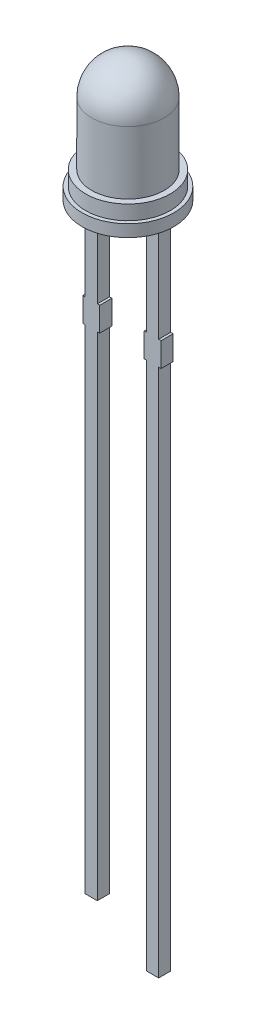
from build123d import *

# Parameters (mm, degrees)
SKETCH2_R          = 1.9
SKETCH2_R_2        = 1.75
EXTRUDE2_DEPTH     = 0.5
SKETCH2_3_R        = 1.75
EXTRUDE3_DEPTH     = 1.1
SKETCH3_3_W        = 0.5
SKETCH3_3_H        = 4.1
SKETCH3_3_H_2      = 1
SKETCH3_3_H_3      = 20.4
SKETCH3_3_W_2      = 0.1
SKETCH3_3_H_4      = 21.9
EXTRUDE4_DEPTH     = 0.25
CUT_EXTRUDE1_DEPTH = 0.01


with BuildPart() as part:
    # Sketch2 → Extrude2 (new body)
    with BuildSketch(Plane(origin=(0, 0, 0), x_dir=(1, 0, 0), z_dir=(0, 1, 0))):
        with Locations(Location((0, 0, 0), (0, 0, 270))):  # turned: the seam where the file's is
            Circle(SKETCH2_R)
        Circle(SKETCH2_R_2, mode=Mode.SUBTRACT)
        Circle(SKETCH2_R_2)
    extrude(amount=EXTRUDE2_DEPTH)

    # Sketch2_3 → Extrude3 (add)
    with BuildSketch(Plane(origin=(0, 0, 0), x_dir=(1, 0, 0), z_dir=(0, 1, 0))):
        with Locations(Location((0, 0, 0), (0, 0, 270))):  # turned: the seam where the file's is
            Circle(SKETCH2_3_R)
    extrude(amount=EXTRUDE3_DEPTH)

    # Sketch3 → Revolve1 (revolve)
    with BuildSketch(Plane.XY, mode=Mode.PRIVATE) as revolve1_sk:
        with BuildLine():
            ThreePointArc((0, 5.2), (1.060660172, 4.760660172), (1.5, 3.7))
            Line((1.5, 3.7), (1.5, 1.1))
            Line((1.5, 1.1), (0, 1.1))
            Line((0, 1.1), (0, 5.2))
        make_face()
    revolve(revolve1_sk.sketch.rotate(Axis((0, 1.1, 0), (0, 1, 0)), 270), axis=Axis((0, 1.1, 0), (0, 1, 0)))  # turned: the seam where the file's is

    # Sketch3_3 → Extrude4 (add, symmetric)
    with BuildSketch(Plane.XY):
        with Locations((-1.27, -2.05)):
            Rectangle(SKETCH3_3_W, SKETCH3_3_H)
        with Locations((-1.27, -4.6)):
            Rectangle(SKETCH3_3_W, SKETCH3_3_H_2)
        with Locations((-1.27, -15.3)):
            Rectangle(SKETCH3_3_W, SKETCH3_3_H_3)
        with Locations((-0.97, -4.6)):
            Rectangle(SKETCH3_3_W_2, SKETCH3_3_H_2)
        with Locations((-1.57, -4.6)):
            Rectangle(SKETCH3_3_W_2, SKETCH3_3_H_2)
        with Locations((1.27, -2.05)):
            Rectangle(SKETCH3_3_W, SKETCH3_3_H)
        with Locations((1.27, -4.6)):
            Rectangle(SKETCH3_3_W, SKETCH3_3_H_2)
        with Locations((0.97, -4.6)):
            Rectangle(SKETCH3_3_W_2, SKETCH3_3_H_2)
        with Locations((1.57, -4.6)):
            Rectangle(SKETCH3_3_W_2, SKETCH3_3_H_2)
        with Locations((1.27, -16.05)):
            Rectangle(SKETCH3_3_W, SKETCH3_3_H_4)
    extrude(amount=EXTRUDE4_DEPTH, both=True)

    # Sketch5 → Cut-Extrude1 (cut)
    with BuildSketch(Plane.XZ):
        Polygon((-0.503821859, -0.079608343), (-0.525576666, -0.152685266), (-0.541832676, -0.152685266), (-0.554062243, -0.101753776), (-0.567944455, -0.152685266), (-0.58411032, -0.152685266), (-0.605744936, -0.079608343), (-0.586994936, -0.079608343), (-0.576027388, -0.132432863), (-0.562956474, -0.079608343), (-0.544777388, -0.079608343), (-0.533359118, -0.132432863), (-0.522662003, -0.079608343), align=None)
        Polygon((-0.403821859, -0.079608343), (-0.425576666, -0.152685266), (-0.441832676, -0.152685266), (-0.454062243, -0.101753776), (-0.467944455, -0.152685266), (-0.48411032, -0.152685266), (-0.505744936, -0.079608343), (-0.486994936, -0.079608343), (-0.476027388, -0.132432863), (-0.462956474, -0.079608343), (-0.444777388, -0.079608343), (-0.433359118, -0.132432863), (-0.422662003, -0.079608343), align=None)
        Polygon((-0.303821859, -0.079608343), (-0.325576666, -0.152685266), (-0.341832676, -0.152685266), (-0.354062243, -0.101753776), (-0.367944455, -0.152685266), (-0.38411032, -0.152685266), (-0.405744936, -0.079608343), (-0.386994936, -0.079608343), (-0.376027388, -0.132432863), (-0.362956474, -0.079608343), (-0.344777388, -0.079608343), (-0.333359118, -0.132432863), (-0.322662003, -0.079608343), align=None)
        with BuildLine():
            add(Edge.make_bspline(
                [(-0.263437243, -0.140185266), (-0.263486727, -0.140892123), (-0.263589513, -0.142360404), (-0.264357807, -0.144504784), (-0.265496591, -0.146613821), (-0.267134075, -0.148533963), (-0.269231655, -0.150213853), (-0.271742782, -0.151593586), (-0.274683068, -0.152530556), (-0.276781381, -0.152632729), (-0.27786032, -0.152685266)],
                knots=[0, 0, 0, 0, 0.803957419, 1.669978378, 2.568830098, 3.52434643, 4.522321038, 5.61514242, 6.773720829, 8, 8, 8, 8], degree=3))
            add(Edge.make_bspline(
                [(-0.27786032, -0.152685266), (-0.278697543, -0.152641732), (-0.280376311, -0.152554437), (-0.282771356, -0.151766833), (-0.284945412, -0.150603694), (-0.286817544, -0.149054517), (-0.288276376, -0.147145358), (-0.289485961, -0.145048644), (-0.290224996, -0.142676212), (-0.29031489, -0.141021518), (-0.29036032, -0.140185266)],
                knots=[0, 0, 0, 0, 1.021956945, 2.049191568, 3.052757421, 4.027239216, 4.995768388, 5.977850542, 6.978043055, 8, 8, 8, 8], degree=3))
            add(Edge.make_bspline(
                [(-0.29036032, -0.140185266), (-0.290317026, -0.139348095), (-0.290231854, -0.137701173), (-0.28947004, -0.135355324), (-0.288323864, -0.133246603), (-0.286823688, -0.131379472), (-0.284984748, -0.12977993), (-0.282769165, -0.128652231), (-0.280383455, -0.127805435), (-0.278698903, -0.127725205), (-0.27786032, -0.127685266)],
                knots=[0, 0, 0, 0, 1.02256761, 2.011643391, 2.988402578, 3.947919371, 4.930894396, 5.945859716, 6.97743239, 8, 8, 8, 8], degree=3))
            add(Edge.make_bspline(
                [(-0.27786032, -0.127685266), (-0.276809681, -0.12773535), (-0.274735014, -0.127834249), (-0.271838649, -0.128841062), (-0.269237757, -0.130131922), (-0.267164407, -0.13189148), (-0.265493452, -0.133795438), (-0.264322082, -0.135875074), (-0.263594766, -0.138025011), (-0.263488734, -0.139479135), (-0.263437243, -0.140185266)],
                knots=[0, 0, 0, 0, 1.193718436, 2.357200027, 3.46616707, 4.488721408, 5.436751473, 6.342315378, 7.195018269, 8, 8, 8, 8], degree=3))
        make_face()
        with BuildLine():
            add(Edge.make_bspline(
                [(-0.203100705, -0.154608343), (-0.204814974, -0.154585883), (-0.208130579, -0.154542441), (-0.212935142, -0.154027673), (-0.217416087, -0.153318314), (-0.221556667, -0.152225485), (-0.225361515, -0.150850333), (-0.228836787, -0.149171492), (-0.232054021, -0.147304786), (-0.234910629, -0.145081561), (-0.237469593, -0.142664532), (-0.239689243, -0.140000479), (-0.241624731, -0.137158483), (-0.243214822, -0.134031891), (-0.244455434, -0.130591099), (-0.245334898, -0.126767024), (-0.245946211, -0.122555462), (-0.246066822, -0.119604606), (-0.246129551, -0.118069882)],
                knots=[0, 0, 0, 0, 1.28338536, 2.482222902, 3.615641418, 4.678302996, 5.684574369, 6.640891817, 7.565949061, 8.464746586, 9.345581526, 10.197575617, 11.056903422, 11.91580542, 12.817603529, 13.789275343, 14.850214295, 16, 16, 16, 16], degree=3))
            Line((-0.246129551, -0.118069882), (-0.227109118, -0.118069882))
            add(Edge.make_bspline(
                [(-0.227109118, -0.118069882), (-0.226986998, -0.119294298), (-0.226756627, -0.121604063), (-0.226159906, -0.124820467), (-0.225407892, -0.127595585), (-0.224389822, -0.129922514), (-0.223231903, -0.131907604), (-0.221939877, -0.133640233), (-0.220584372, -0.135201808), (-0.218602446, -0.136973774), (-0.215830994, -0.1387379), (-0.212116798, -0.140200499), (-0.208023078, -0.141002153), (-0.205177484, -0.141097405), (-0.203701666, -0.141146805)],
                knots=[0, 0, 0, 0, 1.193967772, 2.252326225, 3.172507138, 3.978093684, 4.710151129, 5.398551009, 6.073569162, 6.713873795, 7.973381569, 9.239028936, 10.568070259, 12, 12, 12, 12], degree=3))
            add(Edge.make_bspline(
                [(-0.203701666, -0.141146805), (-0.202134828, -0.141102677), (-0.199167845, -0.141019116), (-0.194986092, -0.140190627), (-0.191343986, -0.138900009), (-0.188278009, -0.137080842), (-0.185834196, -0.134833314), (-0.183995897, -0.132228144), (-0.18285042, -0.129206008), (-0.182730161, -0.127054397), (-0.182668013, -0.125942478)],
                knots=[0, 0, 0, 0, 1.292881893, 2.448216373, 3.505729005, 4.47062867, 5.372299035, 6.228402631, 7.084466243, 8, 8, 8, 8], degree=3))
            add(Edge.make_bspline(
                [(-0.182668013, -0.125942478), (-0.182721517, -0.124822933), (-0.182820838, -0.122744675), (-0.183659336, -0.120299705), (-0.184707409, -0.118677821), (-0.185697877, -0.117543914), (-0.186929699, -0.116471806), (-0.188412505, -0.115490457), (-0.190161617, -0.114557564), (-0.192160794, -0.11362566), (-0.194466584, -0.112762806), (-0.197057579, -0.111925823), (-0.199963537, -0.111101525), (-0.203172508, -0.110167392), (-0.206756434, -0.109334568), (-0.209250991, -0.10873651), (-0.210552628, -0.108424449)],
                knots=[0, 0, 0, 0, 1.308217091, 2.428499093, 2.971811445, 3.562083625, 4.185450824, 4.878313926, 5.639298351, 6.505129032, 7.459166185, 8.51991211, 9.692741175, 10.996059842, 12.432571982, 14, 14, 14, 14], degree=3))
            add(Edge.make_bspline(
                [(-0.210552628, -0.108424449), (-0.211836723, -0.108112066), (-0.214325325, -0.10750666), (-0.217940452, -0.106484683), (-0.221302917, -0.10534421), (-0.224455444, -0.104154737), (-0.227346226, -0.102829375), (-0.229997306, -0.101399394), (-0.23237282, -0.099831824), (-0.234499885, -0.098180881), (-0.236356204, -0.096389924), (-0.237959605, -0.094455661), (-0.239317243, -0.092382215), (-0.240415569, -0.090151978), (-0.241252306, -0.087769484), (-0.241853475, -0.085221755), (-0.242218017, -0.082513548), (-0.242261271, -0.080651161), (-0.242283397, -0.079698488)],
                knots=[0, 0, 0, 0, 1.350138021, 2.616595417, 3.836558268, 4.976793827, 6.057431512, 7.083186274, 8.051004732, 8.961973241, 9.830394181, 10.680720399, 11.523687559, 12.356594861, 13.21427804, 14.097880016, 15.027001965, 16, 16, 16, 16], degree=3))
            add(Edge.make_bspline(
                [(-0.242283397, -0.079698488), (-0.242243964, -0.078665309), (-0.242166202, -0.076627894), (-0.241693688, -0.07363471), (-0.240829468, -0.070776371), (-0.239658736, -0.068045876), (-0.238192264, -0.065460999), (-0.236419325, -0.063067455), (-0.234414286, -0.060844368), (-0.232134525, -0.058813442), (-0.229611232, -0.056993699), (-0.226866576, -0.055351626), (-0.223866748, -0.053978199), (-0.22065337, -0.052805652), (-0.217236142, -0.051878377), (-0.213648115, -0.051222822), (-0.209910813, -0.050821613), (-0.20736855, -0.050782224), (-0.206075465, -0.050762189)],
                knots=[0, 0, 0, 0, 0.957814223, 1.888799201, 2.799332819, 3.718439235, 4.637311203, 5.547134667, 6.473851604, 7.407471124, 8.371205588, 9.353539842, 10.366965553, 11.424217362, 12.520959394, 13.644407811, 14.801862002, 16, 16, 16, 16], degree=3))
            add(Edge.make_bspline(
                [(-0.206075465, -0.050762189), (-0.204622608, -0.050796636), (-0.201771766, -0.050864227), (-0.197576664, -0.051230223), (-0.193578081, -0.051978249), (-0.189745153, -0.052923965), (-0.186126317, -0.054149423), (-0.182730629, -0.055622578), (-0.179599692, -0.057363678), (-0.176748292, -0.059357591), (-0.174153014, -0.061507811), (-0.171879103, -0.063854155), (-0.169980353, -0.066399677), (-0.168381922, -0.069123299), (-0.167078752, -0.072138931), (-0.166178881, -0.075551552), (-0.165578707, -0.079368622), (-0.165435394, -0.08204991), (-0.16536032, -0.083454497)],
                knots=[0, 0, 0, 0, 1.186950675, 2.32907279, 3.434719709, 4.506181443, 5.551366779, 6.551492465, 7.525684865, 8.472032948, 9.389619293, 10.274870494, 11.133875947, 11.977154569, 12.849419986, 13.808029842, 14.851741326, 16, 16, 16, 16], degree=3))
            Line((-0.16536032, -0.083454497), (-0.184440849, -0.083454497))
            add(Edge.make_bspline(
                [(-0.184440849, -0.083454497), (-0.184633942, -0.081943168), (-0.185000689, -0.079072645), (-0.186262262, -0.075089431), (-0.188114566, -0.071720799), (-0.190504546, -0.0689196), (-0.193502328, -0.066781919), (-0.197046996, -0.065271878), (-0.201123558, -0.064374713), (-0.204017421, -0.064275659), (-0.205534599, -0.064223728)],
                knots=[0, 0, 0, 0, 1.138878594, 2.163113395, 3.106118689, 3.999005743, 4.895818561, 5.835958478, 6.865448045, 8, 8, 8, 8], degree=3))
            add(Edge.make_bspline(
                [(-0.205534599, -0.064223728), (-0.206858901, -0.064271531), (-0.209365558, -0.064362012), (-0.212913527, -0.064987723), (-0.215959191, -0.066178946), (-0.218553684, -0.067764277), (-0.220597408, -0.069857544), (-0.222043307, -0.072423353), (-0.222934148, -0.075423889), (-0.223011907, -0.077578553), (-0.223052628, -0.078706901)],
                knots=[0, 0, 0, 0, 1.229005574, 2.326279772, 3.32381644, 4.246881527, 5.127569263, 6.005949281, 6.955762047, 8, 8, 8, 8], degree=3))
            add(Edge.make_bspline(
                [(-0.223052628, -0.078706901), (-0.223012129, -0.079731993), (-0.222937918, -0.081610362), (-0.222271811, -0.084204404), (-0.220991467, -0.086248918), (-0.219213057, -0.087966144), (-0.216687601, -0.089318378), (-0.21342865, -0.090670661), (-0.20925811, -0.091966621), (-0.206150471, -0.092718986), (-0.204452868, -0.093129978)],
                knots=[0, 0, 0, 0, 0.944171751, 1.730091105, 2.434406385, 3.13926556, 3.982880664, 5.054072901, 6.39073578, 8, 8, 8, 8], degree=3))
            add(Edge.make_bspline(
                [(-0.204452868, -0.093129978), (-0.20241596, -0.093565211), (-0.198559063, -0.094389328), (-0.193148523, -0.095793422), (-0.1883597, -0.097126619), (-0.185409074, -0.098107137), (-0.184020176, -0.09856868)],
                knots=[0, 0, 0, 0, 1.181242773, 2.236690395, 3.169987357, 4, 4, 4, 4], degree=3))
            add(Edge.make_bspline(
                [(-0.184020176, -0.09856868), (-0.182493183, -0.099187803), (-0.179593971, -0.100363295), (-0.175627912, -0.102563136), (-0.17216815, -0.105102403), (-0.169179731, -0.108083875), (-0.166680769, -0.111524061), (-0.164851807, -0.115403642), (-0.163649559, -0.11964243), (-0.163509042, -0.122598896), (-0.163437243, -0.124109545)],
                knots=[0, 0, 0, 0, 1.12559323, 2.137097481, 3.091563588, 4.050170991, 5.011659374, 5.982488114, 6.969123197, 8, 8, 8, 8], degree=3))
            add(Edge.make_bspline(
                [(-0.163437243, -0.124109545), (-0.16346924, -0.125144124), (-0.163532442, -0.127187695), (-0.164121187, -0.130204625), (-0.164956032, -0.133159293), (-0.166260271, -0.135975891), (-0.167789734, -0.138698876), (-0.169738198, -0.141190496), (-0.171879037, -0.143583361), (-0.174366596, -0.145753181), (-0.177138783, -0.14769236), (-0.180173635, -0.149465845), (-0.183507481, -0.150969461), (-0.187074891, -0.152297463), (-0.190850592, -0.153355671), (-0.194807639, -0.154051611), (-0.198902422, -0.154528285), (-0.201687036, -0.154581386), (-0.203100705, -0.154608343)],
                knots=[0, 0, 0, 0, 0.891235748, 1.760430872, 2.64325458, 3.532604557, 4.430471646, 5.330579775, 6.253890478, 7.196515965, 8.169562172, 9.16815398, 10.223350337, 11.319304113, 12.44891929, 13.599348363, 14.781258036, 16, 16, 16, 16], degree=3))
        make_face()
        with BuildLine():
            add(Edge.make_bspline(
                [(-0.105744936, -0.144992959), (-0.106194197, -0.145758563), (-0.10707565, -0.147260681), (-0.108759185, -0.149251444), (-0.110736017, -0.150915275), (-0.112987697, -0.152279328), (-0.115510647, -0.153332798), (-0.118309395, -0.154079258), (-0.121375426, -0.15452864), (-0.123511792, -0.154581199), (-0.124615128, -0.154608343)],
                knots=[0, 0, 0, 0, 0.951672298, 1.867185576, 2.782698853, 3.71392514, 4.682455292, 5.707525699, 6.816041397, 8, 8, 8, 8], degree=3))
            add(Edge.make_bspline(
                [(-0.124615128, -0.154608343), (-0.125637266, -0.154580556), (-0.127625879, -0.154526496), (-0.130515384, -0.154244563), (-0.133198674, -0.153696781), (-0.135694218, -0.152955419), (-0.137970846, -0.151953628), (-0.140083345, -0.150781261), (-0.141978002, -0.149361672), (-0.143676726, -0.147728806), (-0.145157676, -0.145871805), (-0.146449594, -0.143813074), (-0.147584325, -0.141550977), (-0.148429701, -0.139034473), (-0.149122314, -0.136322447), (-0.149631607, -0.133400227), (-0.149934284, -0.130265856), (-0.149961621, -0.128106636), (-0.149975705, -0.126994161)],
                knots=[0, 0, 0, 0, 1.141517227, 2.220869849, 3.236285704, 4.194941571, 5.121491616, 6.007825957, 6.886792942, 7.75675051, 8.631724762, 9.531432414, 10.466647329, 11.449839378, 12.488631973, 13.589891555, 14.758261493, 16, 16, 16, 16], degree=3))
            Line((-0.149975705, -0.126994161), (-0.149975705, -0.079608343))
            Line((-0.149975705, -0.079608343), (-0.130744936, -0.079608343))
            Line((-0.130744936, -0.079608343), (-0.130744936, -0.126904016))
            add(Edge.make_bspline(
                [(-0.130744936, -0.126904016), (-0.1307151, -0.128226803), (-0.13066092, -0.130628959), (-0.130315086, -0.133884568), (-0.129655792, -0.13641984), (-0.128719626, -0.138334425), (-0.127427112, -0.139642455), (-0.125912977, -0.140532096), (-0.124137126, -0.141052026), (-0.122875933, -0.141114095), (-0.122211282, -0.141146805)],
                knots=[0, 0, 0, 0, 1.670420621, 3.033453265, 4.122593961, 4.965404288, 5.689746319, 6.409770491, 7.161946514, 8, 8, 8, 8], degree=3))
            add(Edge.make_bspline(
                [(-0.122211282, -0.141146805), (-0.121467466, -0.141120167), (-0.119974177, -0.141066688), (-0.117770557, -0.140558674), (-0.115615055, -0.13976373), (-0.113498094, -0.13868939), (-0.111478239, -0.137236161), (-0.109491597, -0.135522327), (-0.107551151, -0.1334878), (-0.106362634, -0.131963207), (-0.105744936, -0.131170843)],
                knots=[0, 0, 0, 0, 0.891993808, 1.790772165, 2.70010969, 3.646775564, 4.631044069, 5.679839113, 6.794162298, 8, 8, 8, 8], degree=3))
            Line((-0.105744936, -0.131170843), (-0.105744936, -0.079608343))
            Line((-0.105744936, -0.079608343), (-0.086514166, -0.079608343))
            Line((-0.086514166, -0.079608343), (-0.086514166, -0.152685266))
            Line((-0.086514166, -0.152685266), (-0.105744936, -0.152685266))
            Line((-0.105744936, -0.152685266), (-0.105744936, -0.144992959))
        make_face()
        with BuildLine():
            add(Edge.make_bspline(
                [(-0.051898782, -0.087300651), (-0.051500693, -0.086535633), (-0.050722822, -0.085040779), (-0.049192988, -0.083068124), (-0.047433828, -0.081390191), (-0.045422484, -0.080024189), (-0.043162558, -0.078958418), (-0.040658151, -0.078224961), (-0.03791353, -0.077760259), (-0.036005363, -0.077710945), (-0.035011763, -0.077685266)],
                knots=[0, 0, 0, 0, 1.00143585, 1.95681651, 2.888024611, 3.818649522, 4.772323889, 5.782194879, 6.845168342, 8, 8, 8, 8], degree=3))
            add(Edge.make_bspline(
                [(-0.035011763, -0.077685266), (-0.033909533, -0.077712883), (-0.031771048, -0.077766464), (-0.02866218, -0.078049396), (-0.025770167, -0.078599004), (-0.023072557, -0.079331344), (-0.020610762, -0.080343616), (-0.018324615, -0.08149173), (-0.016300411, -0.082941038), (-0.014452452, -0.084550131), (-0.012850311, -0.086410949), (-0.011460269, -0.088468724), (-0.010278541, -0.090746309), (-0.009325151, -0.093249216), (-0.008578404, -0.095966562), (-0.008033243, -0.098890399), (-0.007748978, -0.102028623), (-0.007695546, -0.104187168), (-0.007668013, -0.105299449)],
                knots=[0, 0, 0, 0, 1.186832343, 2.3026268, 3.355761513, 4.352522852, 5.305579363, 6.217046986, 7.099481147, 7.977887867, 8.849185092, 9.734381594, 10.645849217, 11.604985507, 12.612131568, 13.675865719, 14.802392456, 16, 16, 16, 16], degree=3))
            Line((-0.007668013, -0.105299449), (-0.007668013, -0.152685266))
            Line((-0.007668013, -0.152685266), (-0.026898782, -0.152685266))
            Line((-0.026898782, -0.152685266), (-0.026898782, -0.105389593))
            add(Edge.make_bspline(
                [(-0.026898782, -0.105389593), (-0.026923757, -0.104156263), (-0.02696985, -0.101880111), (-0.027387044, -0.098761255), (-0.028142971, -0.096233965), (-0.02924859, -0.094263077), (-0.030737369, -0.092780042), (-0.032657442, -0.091834548), (-0.034922904, -0.091212402), (-0.036569398, -0.09116959), (-0.037445657, -0.091146805)],
                knots=[0, 0, 0, 0, 1.441015903, 2.659442997, 3.666423338, 4.505664336, 5.275500286, 6.081849636, 6.979166905, 8, 8, 8, 8], degree=3))
            add(Edge.make_bspline(
                [(-0.037445657, -0.091146805), (-0.038018832, -0.091178991), (-0.039179962, -0.091244194), (-0.04093973, -0.091687521), (-0.042697321, -0.092453246), (-0.044497859, -0.093497476), (-0.046316418, -0.094830727), (-0.048200641, -0.096422175), (-0.050045478, -0.098373939), (-0.05126362, -0.099785691), (-0.051898782, -0.100521805)],
                knots=[0, 0, 0, 0, 0.774464777, 1.568897174, 2.436202086, 3.357883609, 4.375901529, 5.479906668, 6.685976861, 8, 8, 8, 8], degree=3))
            Line((-0.051898782, -0.100521805), (-0.051898782, -0.152685266))
            Line((-0.051898782, -0.152685266), (-0.071129551, -0.152685266))
            Line((-0.071129551, -0.152685266), (-0.071129551, -0.079608343))
            Line((-0.071129551, -0.079608343), (-0.051898782, -0.079608343))
            Line((-0.051898782, -0.079608343), (-0.051898782, -0.087300651))
        make_face()
        Polygon((0.076947372, -0.152685266), (0.00963968, -0.152685266), (0.00963968, -0.052685266), (0.028870449, -0.052685266), (0.028870449, -0.139223728), (0.076947372, -0.139223728), align=None)
        Polygon((0.167331987, -0.152685266), (0.088485834, -0.152685266), (0.088485834, -0.052685266), (0.16540891, -0.052685266), (0.16540891, -0.066146805), (0.107716603, -0.066146805), (0.107716603, -0.094992959), (0.161562757, -0.094992959), (0.161562757, -0.108454497), (0.107716603, -0.108454497), (0.107716603, -0.139223728), (0.167331987, -0.139223728), align=None)
        with BuildLine():
            add(Edge.make_bspline(
                [(0.269255064, -0.102144401), (0.269217576, -0.10418939), (0.269144979, -0.108149495), (0.268503613, -0.113898833), (0.267461195, -0.119246524), (0.266035508, -0.124222543), (0.264134463, -0.128787847), (0.261805807, -0.132953554), (0.259104748, -0.136763696), (0.255897084, -0.140099239), (0.252344964, -0.143124835), (0.248299853, -0.145654916), (0.243897563, -0.147877965), (0.239040898, -0.149640828), (0.233777165, -0.151007108), (0.228100773, -0.15200024), (0.222010604, -0.152556769), (0.217813874, -0.152641542), (0.215649295, -0.152685266)],
                knots=[0, 0, 0, 0, 1.161219646, 2.24869368, 3.280708715, 4.252829228, 5.183621711, 6.082630713, 6.958888302, 7.828118733, 8.704376322, 9.602322718, 10.530939534, 11.501077163, 12.530454616, 13.6163204, 14.770551419, 16, 16, 16, 16], degree=3))
            Line((0.215649295, -0.152685266), (0.182716603, -0.152685266))
            Line((0.182716603, -0.152685266), (0.182716603, -0.052685266))
            Line((0.182716603, -0.052685266), (0.215649295, -0.052685266))
            add(Edge.make_bspline(
                [(0.215649295, -0.052685266), (0.217814422, -0.052711708), (0.222013461, -0.052762989), (0.228095977, -0.053390164), (0.233775445, -0.054330629), (0.239042092, -0.055665575), (0.243877744, -0.057418646), (0.248317558, -0.059518651), (0.252319068, -0.062045876), (0.255918713, -0.064963061), (0.259081588, -0.068273529), (0.261808321, -0.071990241), (0.264132914, -0.076070482), (0.266036718, -0.080544758), (0.267452577, -0.085413698), (0.268511182, -0.090648247), (0.269141463, -0.096269646), (0.26921649, -0.100149592), (0.269255064, -0.102144401)],
                knots=[0, 0, 0, 0, 1.24197401, 2.408678741, 3.504780762, 4.5433438, 5.521527764, 6.452152268, 7.356290842, 8.230615943, 9.104657617, 9.976030571, 10.869306848, 11.793823342, 12.759447772, 13.773938722, 14.855507726, 16, 16, 16, 16], degree=3))
        make_face()
        with BuildLine():
            add(Edge.make_bspline(
                [(0.250024295, -0.102114353), (0.25001408, -0.10073124), (0.249994209, -0.098040848), (0.249635916, -0.094121216), (0.249147301, -0.090414254), (0.248419758, -0.086932187), (0.247531526, -0.083668126), (0.24627077, -0.080711618), (0.244810182, -0.077994942), (0.2430147, -0.075582918), (0.240941786, -0.073390055), (0.238487594, -0.071508889), (0.235686654, -0.0698633), (0.232500932, -0.068520906), (0.228928162, -0.067437343), (0.224922799, -0.066660928), (0.220476713, -0.066226664), (0.217363003, -0.066174174), (0.215739439, -0.066146805)],
                knots=[0, 0, 0, 0, 1.149495408, 2.235966294, 3.270011624, 4.256484947, 5.192194903, 6.076854796, 6.922927111, 7.750728226, 8.569431422, 9.423985878, 10.312361613, 11.263690782, 12.291074984, 13.411453686, 14.650268675, 16, 16, 16, 16], degree=3))
            Line((0.215739439, -0.066146805), (0.201947372, -0.066146805))
            Line((0.201947372, -0.066146805), (0.201947372, -0.139223728))
            Line((0.201947372, -0.139223728), (0.215739439, -0.139223728))
            add(Edge.make_bspline(
                [(0.215739439, -0.139223728), (0.217373408, -0.139200493), (0.220498924, -0.139156048), (0.224951128, -0.138670669), (0.228948045, -0.137905774), (0.232502121, -0.136833767), (0.235642225, -0.135431644), (0.238419871, -0.133769755), (0.240901394, -0.131880726), (0.242987061, -0.129644091), (0.244780204, -0.127147849), (0.246286581, -0.124372416), (0.247481107, -0.121295696), (0.248437196, -0.117954844), (0.249144737, -0.114343447), (0.24964029, -0.110478317), (0.249992285, -0.106377614), (0.25001346, -0.10355745), (0.250024295, -0.102114353)],
                knots=[0, 0, 0, 0, 1.33477961, 2.553215293, 3.654392007, 4.656342135, 5.579650195, 6.456971844, 7.296880229, 8.119053426, 8.945898676, 9.802940951, 10.692095258, 11.637628976, 12.639278173, 13.696155562, 14.821106832, 16, 16, 16, 16], degree=3))
        make_face(mode=Mode.SUBTRACT)
        with BuildLine():
            add(Edge.make_bspline(
                [(0.31540891, -0.140185266), (0.315359427, -0.140892123), (0.315256641, -0.142360404), (0.314488347, -0.144504784), (0.313349563, -0.146613821), (0.311712079, -0.148533963), (0.309614499, -0.150213853), (0.307103372, -0.151593586), (0.304163086, -0.152530556), (0.302064773, -0.152632729), (0.300985834, -0.152685266)],
                knots=[0, 0, 0, 0, 0.803957419, 1.669978378, 2.568830098, 3.52434643, 4.522321038, 5.61514242, 6.773720829, 8, 8, 8, 8], degree=3))
            add(Edge.make_bspline(
                [(0.300985834, -0.152685266), (0.300148611, -0.152641732), (0.298469843, -0.152554437), (0.296074798, -0.151766833), (0.293900742, -0.150603694), (0.29202861, -0.149054517), (0.290569777, -0.147145358), (0.289360193, -0.145048644), (0.288621158, -0.142676212), (0.288531264, -0.141021518), (0.288485834, -0.140185266)],
                knots=[0, 0, 0, 0, 1.021956945, 2.049191568, 3.052757421, 4.027239216, 4.995768388, 5.977850542, 6.978043055, 8, 8, 8, 8], degree=3))
            add(Edge.make_bspline(
                [(0.288485834, -0.140185266), (0.288529128, -0.139348095), (0.2886143, -0.137701173), (0.289376114, -0.135355324), (0.29052229, -0.133246603), (0.292022466, -0.131379472), (0.293861406, -0.12977993), (0.296076989, -0.128652231), (0.298462699, -0.127805435), (0.30014725, -0.127725205), (0.300985834, -0.127685266)],
                knots=[0, 0, 0, 0, 1.02256761, 2.011643391, 2.988402578, 3.947919371, 4.930894396, 5.945859716, 6.97743239, 8, 8, 8, 8], degree=3))
            add(Edge.make_bspline(
                [(0.300985834, -0.127685266), (0.302036473, -0.12773535), (0.30411114, -0.127834249), (0.307007504, -0.128841062), (0.309608396, -0.130131922), (0.311681747, -0.13189148), (0.313352702, -0.133795438), (0.314524072, -0.135875074), (0.315251388, -0.138025011), (0.31535742, -0.139479135), (0.31540891, -0.140185266)],
                knots=[0, 0, 0, 0, 1.193718436, 2.357200027, 3.46616707, 4.488721408, 5.436751473, 6.342315378, 7.195018269, 8, 8, 8, 8], degree=3))
        make_face()
        with BuildLine():
            add(Edge.make_bspline(
                [(0.365859632, -0.154608343), (0.364575259, -0.154587683), (0.362055833, -0.154547157), (0.358374266, -0.153985693), (0.354836084, -0.15324787), (0.351503148, -0.152082578), (0.348366038, -0.150661471), (0.345482283, -0.148877581), (0.342796673, -0.14685394), (0.340388163, -0.144481549), (0.338213937, -0.141853509), (0.336281255, -0.138958555), (0.334633117, -0.135790268), (0.333247612, -0.132369755), (0.332122137, -0.128694677), (0.331367899, -0.124745038), (0.330862422, -0.120536914), (0.330816972, -0.117640792), (0.330793526, -0.116146805)],
                knots=[0, 0, 0, 0, 1.047336758, 2.054456287, 3.03439317, 3.993646679, 4.930156219, 5.840202366, 6.755960155, 7.669488798, 8.592807151, 9.536144313, 10.505277466, 11.502793093, 12.545139458, 13.637098113, 14.781077921, 16, 16, 16, 16], degree=3))
            add(Edge.make_bspline(
                [(0.330793526, -0.116146805), (0.330817978, -0.114682982), (0.330865683, -0.111827095), (0.331364352, -0.107667575), (0.332135484, -0.103745674), (0.333214547, -0.100060786), (0.334604614, -0.096624596), (0.336245449, -0.093438702), (0.338162915, -0.090522186), (0.340315536, -0.087859612), (0.342776913, -0.085526558), (0.345420545, -0.083411277), (0.348359969, -0.081684361), (0.351499942, -0.080234451), (0.354841224, -0.079086406), (0.358369456, -0.078297265), (0.362056526, -0.077749358), (0.364575493, -0.077706907), (0.365859632, -0.077685266)],
                knots=[0, 0, 0, 0, 1.194867585, 2.331162469, 3.415519797, 4.45592294, 5.461402785, 6.438161706, 7.377349552, 8.307339102, 9.227093374, 10.141741913, 11.066139606, 12.003009567, 12.962632249, 13.944753045, 14.952260169, 16, 16, 16, 16], degree=3))
            add(Edge.make_bspline(
                [(0.365859632, -0.077685266), (0.366912172, -0.077710285), (0.369002322, -0.077759969), (0.372085372, -0.078097431), (0.375091477, -0.078634613), (0.377986204, -0.079410008), (0.380753872, -0.08040889), (0.383365216, -0.081566302), (0.38579464, -0.082927347), (0.388019331, -0.084488519), (0.390034244, -0.086238648), (0.39185747, -0.088140775), (0.393449504, -0.09021595), (0.394835556, -0.092484711), (0.395987444, -0.095015361), (0.396912092, -0.097890554), (0.397668059, -0.101114516), (0.397952988, -0.103412727), (0.398101218, -0.104608343)],
                knots=[0, 0, 0, 0, 1.080765488, 2.146200892, 3.181163785, 4.214080283, 5.219383685, 6.200022783, 7.144110219, 8.074369293, 8.985844923, 9.880687245, 10.775588676, 11.666402291, 12.605320916, 13.623381954, 14.763593765, 16, 16, 16, 16], degree=3))
            Line((0.398101218, -0.104608343), (0.378960593, -0.104608343))
            add(Edge.make_bspline(
                [(0.378960593, -0.104608343), (0.378869435, -0.103440479), (0.378699643, -0.101265219), (0.377893462, -0.098309258), (0.376697489, -0.095872804), (0.374983769, -0.094063904), (0.372970472, -0.092760859), (0.370751007, -0.09182812), (0.368314264, -0.09123316), (0.366614373, -0.091176149), (0.365739439, -0.091146805)],
                knots=[0, 0, 0, 0, 1.312413462, 2.444497233, 3.420095611, 4.326995713, 5.203269489, 6.094987921, 7.019489993, 8, 8, 8, 8], degree=3))
            add(Edge.make_bspline(
                [(0.365739439, -0.091146805), (0.364718698, -0.091194588), (0.362718323, -0.09128823), (0.360353825, -0.09215793), (0.358599817, -0.093106276), (0.357369112, -0.094098418), (0.356164454, -0.095277455), (0.354993707, -0.096655599), (0.353893163, -0.098264712), (0.352950861, -0.100131665), (0.352112065, -0.102226927), (0.351353924, -0.104539408), (0.350757159, -0.107091925), (0.350347466, -0.109896359), (0.350070408, -0.112936151), (0.350039985, -0.115054396), (0.350024295, -0.116146805)],
                knots=[0, 0, 0, 0, 1.294790379, 2.537435469, 3.165661086, 3.829164872, 4.541864701, 5.311227921, 6.128593511, 7.018685834, 7.968657266, 9.00144956, 10.115435461, 11.302621323, 12.608924514, 14, 14, 14, 14], degree=3))
            add(Edge.make_bspline(
                [(0.350024295, -0.116146805), (0.350043376, -0.117248944), (0.350080198, -0.119375826), (0.350310116, -0.12243859), (0.350729322, -0.125261488), (0.351321729, -0.127834219), (0.352073472, -0.130164652), (0.352957839, -0.132244866), (0.353890847, -0.134120607), (0.35530796, -0.136180288), (0.35721493, -0.138266626), (0.359844237, -0.140007196), (0.362714819, -0.140998831), (0.364709959, -0.141096439), (0.365739439, -0.141146805)],
                knots=[0, 0, 0, 0, 1.201885478, 2.31936817, 3.346574926, 4.310947528, 5.195171259, 6.012657592, 6.774708936, 7.474495386, 8.733959456, 9.830591055, 10.880597417, 12, 12, 12, 12], degree=3))
            add(Edge.make_bspline(
                [(0.365739439, -0.141146805), (0.366603777, -0.141114458), (0.368280475, -0.141051711), (0.370681146, -0.140502383), (0.372851703, -0.139594541), (0.37477534, -0.138325323), (0.376393588, -0.136668712), (0.377480874, -0.134976391), (0.378157572, -0.13331837), (0.378515134, -0.131713736), (0.378819894, -0.129807323), (0.378930902, -0.128427717), (0.378990641, -0.127685266)],
                knots=[0, 0, 0, 0, 1.210933032, 2.349044084, 3.43171645, 4.495267269, 5.558075774, 6.656937348, 7.293383625, 8.059914447, 8.955920865, 10, 10, 10, 10], degree=3))
            Line((0.378990641, -0.127685266), (0.398101218, -0.127685266))
            add(Edge.make_bspline(
                [(0.398101218, -0.127685266), (0.397940836, -0.128900649), (0.397633838, -0.131227081), (0.39688081, -0.134504678), (0.395947261, -0.137423125), (0.394708339, -0.139952844), (0.393308263, -0.142218257), (0.391697802, -0.144275802), (0.389884555, -0.146175214), (0.387881512, -0.147918972), (0.38566672, -0.149454338), (0.383282392, -0.150808943), (0.380723353, -0.151988016), (0.377992921, -0.152937351), (0.37512937, -0.153688178), (0.372147614, -0.154236924), (0.36904038, -0.154525321), (0.366931866, -0.154580356), (0.365859632, -0.154608343)],
                knots=[0, 0, 0, 0, 1.258051893, 2.408109002, 3.448772144, 4.39629231, 5.292354794, 6.178984465, 7.073688607, 7.985023489, 8.900815369, 9.83580737, 10.797563429, 11.78957876, 12.799817111, 13.834620187, 14.898848121, 16, 16, 16, 16], degree=3))
        make_face()
        with BuildLine():
            add(Edge.make_bspline(
                [(0.438485834, -0.077685266), (0.439879953, -0.077718014), (0.442608994, -0.077782118), (0.446603792, -0.078340623), (0.450402621, -0.079230403), (0.453993554, -0.080503046), (0.457345977, -0.08208496), (0.460430291, -0.083954626), (0.463229146, -0.086094771), (0.465688862, -0.088555007), (0.467900803, -0.091231168), (0.469792547, -0.094161475), (0.471404936, -0.097322758), (0.472702249, -0.100713648), (0.473777563, -0.104293216), (0.474471989, -0.108082946), (0.474945038, -0.112048287), (0.474997538, -0.114763127), (0.475024295, -0.116146805)],
                knots=[0, 0, 0, 0, 1.116475797, 2.185542979, 3.224923316, 4.237598129, 5.231919818, 6.189791294, 7.122353009, 8.047287697, 8.971003188, 9.899169676, 10.835865412, 11.808977354, 12.804367075, 13.825779647, 14.891860981, 16, 16, 16, 16], degree=3))
            add(Edge.make_bspline(
                [(0.475024295, -0.116146805), (0.47499757, -0.117550406), (0.4749455, -0.120285071), (0.474476648, -0.124293822), (0.473743228, -0.12809712), (0.472688386, -0.131700082), (0.471327814, -0.135075204), (0.469710154, -0.138241247), (0.467801054, -0.141184754), (0.465609602, -0.143887932), (0.46313659, -0.146346326), (0.460348582, -0.148492598), (0.457253079, -0.150327296), (0.453902367, -0.151881587), (0.450310786, -0.153122956), (0.446521856, -0.153981714), (0.442556803, -0.154502423), (0.43985963, -0.154572599), (0.438485834, -0.154608343)],
                knots=[0, 0, 0, 0, 1.123562633, 2.189060306, 3.227190231, 4.222034994, 5.190106252, 6.137083223, 7.064741556, 7.99416643, 8.918594733, 9.850645887, 10.803851701, 11.794224938, 12.803704333, 13.840687306, 14.900160981, 16, 16, 16, 16], degree=3))
            add(Edge.make_bspline(
                [(0.438485834, -0.154608343), (0.437212288, -0.154582761), (0.43471575, -0.154532612), (0.431061225, -0.154042364), (0.427593322, -0.153225633), (0.424300397, -0.152125826), (0.421228184, -0.150678079), (0.418378545, -0.148920009), (0.415750863, -0.146862011), (0.413342168, -0.144523141), (0.411202574, -0.14188025), (0.409294743, -0.138988722), (0.407687839, -0.135811682), (0.406284277, -0.132406311), (0.405205223, -0.128709318), (0.404445228, -0.124755324), (0.403939555, -0.120536773), (0.403893966, -0.117640744), (0.403870449, -0.116146805)],
                knots=[0, 0, 0, 0, 1.045185112, 2.048882016, 3.020291938, 3.966880199, 4.893905909, 5.802213808, 6.710261089, 7.629080276, 8.552524605, 9.496788192, 10.46774551, 11.471038078, 12.517063969, 13.623413772, 14.774018743, 16, 16, 16, 16], degree=3))
            add(Edge.make_bspline(
                [(0.403870449, -0.116146805), (0.403898263, -0.114683402), (0.403952318, -0.111839408), (0.404401705, -0.107685033), (0.405192665, -0.103781081), (0.406228184, -0.100091452), (0.407593935, -0.096657376), (0.409196951, -0.093460724), (0.411121394, -0.090560561), (0.413250783, -0.087891505), (0.415663454, -0.085514694), (0.41831115, -0.08343274), (0.421198907, -0.081674004), (0.424307022, -0.080235974), (0.427608103, -0.079091158), (0.431094686, -0.078293187), (0.434732893, -0.077751451), (0.437221786, -0.077707559), (0.438485834, -0.077685266)],
                knots=[0, 0, 0, 0, 1.201848745, 2.335685805, 3.426378622, 4.470561871, 5.478866717, 6.457570667, 7.402245833, 8.332481093, 9.257462806, 10.17745529, 11.093170774, 12.028051071, 12.98550063, 13.957333963, 14.96257992, 16, 16, 16, 16], degree=3))
        make_face()
        with BuildLine():
            add(Edge.make_bspline(
                [(0.43854593, -0.141146805), (0.439776903, -0.141073111), (0.442162777, -0.140930277), (0.445544772, -0.139775807), (0.448505607, -0.137850416), (0.450592422, -0.135654041), (0.451996951, -0.133527662), (0.452966141, -0.13167619), (0.453793585, -0.129598142), (0.454525252, -0.127302577), (0.455077584, -0.124786574), (0.455504938, -0.122078561), (0.455737348, -0.11917568), (0.455774384, -0.117178834), (0.455793526, -0.116146805)],
                knots=[0, 0, 0, 0, 1.295059177, 2.510086438, 3.716370727, 4.985576951, 5.670626941, 6.397730367, 7.183741792, 8.025007773, 8.934067091, 9.895485546, 10.912324256, 12, 12, 12, 12], degree=3))
            add(Edge.make_bspline(
                [(0.455793526, -0.116146805), (0.455774787, -0.115114728), (0.455738711, -0.113127771), (0.455503392, -0.110245328), (0.455086311, -0.107584932), (0.454515911, -0.105123102), (0.453790481, -0.102866468), (0.452957027, -0.100792599), (0.452002724, -0.098907136), (0.450875273, -0.097246443), (0.449659254, -0.095784265), (0.448338807, -0.094510209), (0.446904743, -0.093472292), (0.444881511, -0.092344043), (0.442101595, -0.091320085), (0.439748286, -0.0912054), (0.43854593, -0.091146805)],
                knots=[0, 0, 0, 0, 1.270965165, 2.446865025, 3.558110639, 4.584301362, 5.555578469, 6.474044422, 7.334617136, 8.152219829, 8.940260781, 9.673084706, 10.405804824, 11.112633012, 12.524781949, 14, 14, 14, 14], degree=3))
            add(Edge.make_bspline(
                [(0.43854593, -0.091146805), (0.43755639, -0.091198961), (0.435610656, -0.091301515), (0.433294523, -0.09212554), (0.431586037, -0.093078321), (0.43037466, -0.094078539), (0.429181583, -0.095279094), (0.428010086, -0.096686438), (0.426915889, -0.098319272), (0.425974491, -0.10019835), (0.425090451, -0.102266122), (0.42437376, -0.104571982), (0.423806444, -0.107114403), (0.423387996, -0.109905076), (0.423156989, -0.112947801), (0.423120258, -0.11505468), (0.423101218, -0.116146805)],
                knots=[0, 0, 0, 0, 1.26445895, 2.48630758, 3.107229898, 3.764753363, 4.49086656, 5.274808243, 6.107862949, 7.003443443, 7.964172427, 8.987193514, 10.092654654, 11.299851966, 12.600347358, 14, 14, 14, 14], degree=3))
            add(Edge.make_bspline(
                [(0.423101218, -0.116146805), (0.423120022, -0.117249), (0.423156309, -0.119375987), (0.423390679, -0.122447901), (0.423799751, -0.125282999), (0.424408288, -0.127858122), (0.425118137, -0.130208114), (0.425998686, -0.13228261), (0.426910971, -0.134164082), (0.428316691, -0.136190739), (0.430177471, -0.138262655), (0.432744587, -0.14001379), (0.435571775, -0.140994399), (0.437536773, -0.141095092), (0.43854593, -0.141146805)],
                knots=[0, 0, 0, 0, 1.20896833, 2.333036478, 3.37716209, 4.347217853, 5.233321318, 6.065764419, 6.817519703, 7.521430076, 8.765288404, 9.850066282, 10.895866793, 12, 12, 12, 12], degree=3))
        make_face(mode=Mode.SUBTRACT)
        with BuildLine():
            Line((0.58463968, -0.152685266), (0.56540891, -0.152685266))
            Line((0.56540891, -0.152685266), (0.56540891, -0.105389593))
            add(Edge.make_bspline(
                [(0.56540891, -0.105389593), (0.565391305, -0.104116339), (0.565359193, -0.101794023), (0.565008546, -0.098632831), (0.56446275, -0.096114593), (0.563605465, -0.094182831), (0.56244143, -0.092770463), (0.560959608, -0.091815319), (0.559182358, -0.091220768), (0.557892058, -0.091172485), (0.557205785, -0.091146805)],
                knots=[0, 0, 0, 0, 1.625158581, 2.964162962, 4.056132934, 4.902993662, 5.638290084, 6.358412536, 7.126888559, 8, 8, 8, 8], degree=3))
            add(Edge.make_bspline(
                [(0.557205785, -0.091146805), (0.556692803, -0.091180241), (0.555640739, -0.091248816), (0.554044611, -0.09168274), (0.552466825, -0.092472718), (0.550811054, -0.093451093), (0.54920697, -0.094811818), (0.547543077, -0.096409732), (0.545858486, -0.098304083), (0.544804906, -0.099721821), (0.544255064, -0.100461709)],
                knots=[0, 0, 0, 0, 0.746304081, 1.530577426, 2.384008794, 3.305666621, 4.320112429, 5.432488578, 6.660070536, 8, 8, 8, 8], degree=3))
            Line((0.544255064, -0.100461709), (0.544255064, -0.152685266))
            Line((0.544255064, -0.152685266), (0.525024295, -0.152685266))
            Line((0.525024295, -0.152685266), (0.525024295, -0.105389593))
            add(Edge.make_bspline(
                [(0.525024295, -0.105389593), (0.525003334, -0.104127156), (0.524964801, -0.101806373), (0.524647776, -0.098643702), (0.524024927, -0.096136366), (0.523205848, -0.094176016), (0.521994428, -0.092780625), (0.520509679, -0.091806161), (0.518715163, -0.091225973), (0.517416614, -0.09117416), (0.516731026, -0.091146805)],
                knots=[0, 0, 0, 0, 1.607824129, 2.955720206, 4.035306498, 4.891351629, 5.632845582, 6.350935609, 7.129352771, 8, 8, 8, 8], degree=3))
            add(Edge.make_bspline(
                [(0.516731026, -0.091146805), (0.5162279, -0.091180099), (0.515195243, -0.091248434), (0.513630695, -0.091685824), (0.512070575, -0.092466425), (0.510473399, -0.093499791), (0.508829238, -0.094804247), (0.507201014, -0.096443741), (0.505501923, -0.098339436), (0.504431074, -0.099752153), (0.503870449, -0.100491757)],
                knots=[0, 0, 0, 0, 0.735154183, 1.508892268, 2.35301314, 3.274245823, 4.284147733, 5.411806025, 6.644995423, 8, 8, 8, 8], degree=3))
            Line((0.503870449, -0.100491757), (0.503870449, -0.152685266))
            Line((0.503870449, -0.152685266), (0.48463968, -0.152685266))
            Line((0.48463968, -0.152685266), (0.48463968, -0.079608343))
            Line((0.48463968, -0.079608343), (0.503870449, -0.079608343))
            Line((0.503870449, -0.079608343), (0.503870449, -0.087300651))
            add(Edge.make_bspline(
                [(0.503870449, -0.087300651), (0.504227824, -0.086536441), (0.504923672, -0.08504844), (0.506331728, -0.083083172), (0.507934926, -0.08140449), (0.509767697, -0.080025524), (0.511842311, -0.078965226), (0.514145597, -0.078223245), (0.51667263, -0.077761581), (0.518431653, -0.077711353), (0.519345209, -0.077685266)],
                knots=[0, 0, 0, 0, 1.039507605, 2.024034437, 2.968382062, 3.895660035, 4.841220903, 5.830394678, 6.873205695, 8, 8, 8, 8], degree=3))
            add(Edge.make_bspline(
                [(0.519345209, -0.077685266), (0.520769315, -0.077716335), (0.523478676, -0.077775444), (0.527311829, -0.078308913), (0.530692049, -0.079197786), (0.533618758, -0.080447379), (0.536084556, -0.08209285), (0.538075416, -0.084115971), (0.539637171, -0.086500301), (0.540228081, -0.088304587), (0.540529103, -0.089223728)],
                knots=[0, 0, 0, 0, 1.309659259, 2.491625798, 3.551159525, 4.516729613, 5.40613012, 6.259724573, 7.113468225, 8, 8, 8, 8], degree=3))
            add(Edge.make_bspline(
                [(0.540529103, -0.089223728), (0.540591976, -0.088695804), (0.54071727, -0.087643762), (0.541403834, -0.086168164), (0.54238111, -0.084781988), (0.544153619, -0.083175371), (0.546507961, -0.08148432), (0.549291168, -0.079811969), (0.551954465, -0.078653002), (0.554558064, -0.078066022), (0.557088274, -0.077770514), (0.558767527, -0.077713738), (0.559609632, -0.077685266)],
                knots=[0, 0, 0, 0, 0.660489503, 1.31621866, 2.00730456, 2.768601672, 4.290578502, 5.625711259, 6.820480423, 7.901183206, 8.947494325, 10, 10, 10, 10], degree=3))
            add(Edge.make_bspline(
                [(0.559609632, -0.077685266), (0.560621797, -0.077712585), (0.56258055, -0.077765452), (0.565429786, -0.07805155), (0.568073032, -0.078597074), (0.570540361, -0.079336302), (0.57278934, -0.080350639), (0.574892377, -0.081492539), (0.576736356, -0.082953025), (0.578431438, -0.084563036), (0.579913552, -0.086414584), (0.581174195, -0.088482275), (0.582273374, -0.090749814), (0.583123288, -0.093258649), (0.583825335, -0.095968095), (0.584284543, -0.098896915), (0.58460134, -0.102027243), (0.584626643, -0.1041868), (0.58463968, -0.105299449)],
                knots=[0, 0, 0, 0, 1.137154058, 2.200633721, 3.211143576, 4.164820371, 5.086644937, 5.978319905, 6.8446531, 7.719852616, 8.600099044, 9.499265429, 10.435192553, 11.424308846, 12.469360708, 13.575369395, 14.750779371, 16, 16, 16, 16], degree=3))
            Line((0.58463968, -0.105299449), (0.58463968, -0.152685266))
        make_face()
    extrude(amount=-CUT_EXTRUDE1_DEPTH, mode=Mode.SUBTRACT)


solid = part.part
